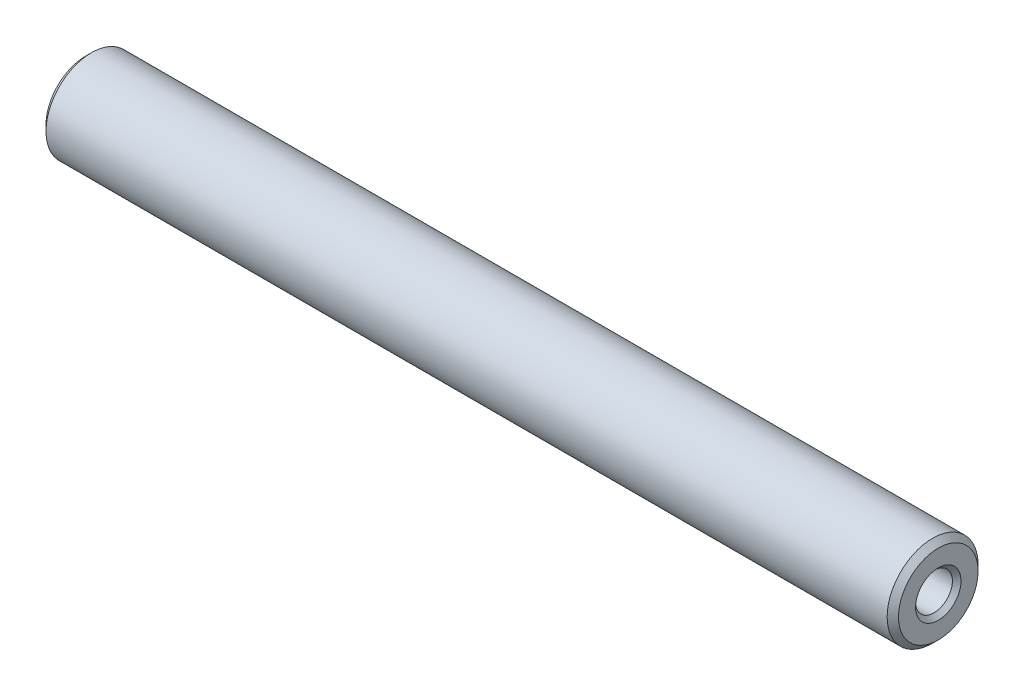
from build123d import *


with BuildPart() as part:
    # Sketch1 → Revolve1 (revolve)
    with BuildSketch(Plane(origin=(0, 0, 0), x_dir=(-1, 0, 0), z_dir=(0, 0, -1))):
        Polygon((-61.935884786, 1.621), (-61.000000004, 6e-09), (-14, 6e-09), (-13.064115214, 1.621), (-0.379, 1.621), (0, 2), (0, 3.5), (-0.5, 4), (-74.5, 4), (-75, 3.5), (-75, 2), (-74.621, 1.621), align=None)
    revolve(axis=Axis((75, 6e-09, 0), (-1, 0, 0)))


solid = part.part
